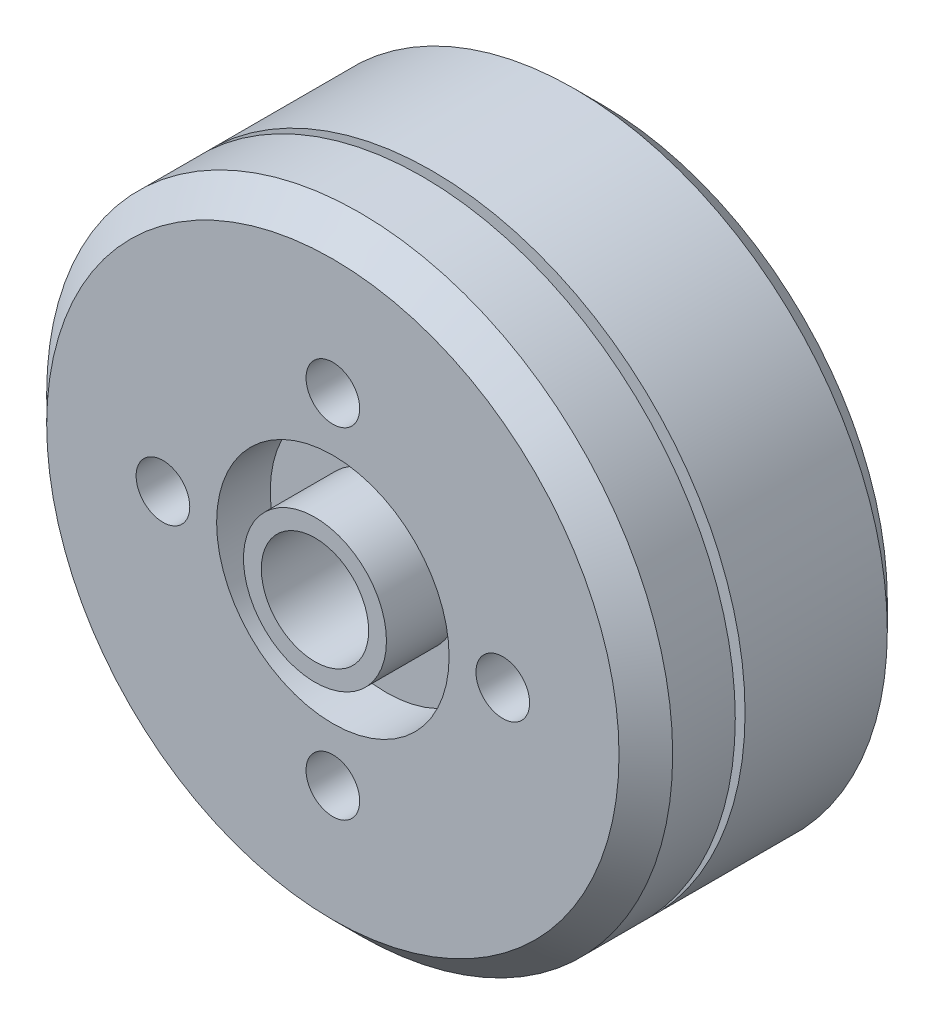
from build123d import *

# Parameters (mm, degrees)
SKETCH_1_R          = 17.5
EXTRUDE_1_DEPTH     = 15
SKETCH_2_R          = 1.5
CUT_EXTRUDE_1_DEPTH = 5
SKETCH_4_R          = 3
CUT_EXTRUDE_2_DEPTH = 20
SKETCH_5_R          = 1.5
CUT_EXTRUDE_3_DEPTH = 6
CHAMFER_1_SIZE      = 1.5
SKETCH_6_R          = 6.5
SKETCH_6_R_2        = 3.996615851
CUT_EXTRUDE_4_DEPTH = 3
SKETCH_7_R          = 3.996615851
SKETCH_7_R_2        = 3
EXTRUDE_2_DEPTH     = 1


with BuildPart() as part:
    # 草图1 → 凸台-拉伸1 (new body)
    with BuildSketch(Plane.XY):
        Circle(SKETCH_1_R)
    extrude(amount=EXTRUDE_1_DEPTH)

    # 草图2 → 切除-拉伸1 (cut)
    with BuildSketch(Plane(origin=(0, 0, 0), x_dir=(-1, 0, 0), z_dir=(0, 0, -1))):
        with Locations((0, -8)):
            Circle(SKETCH_2_R)
        with Locations((-8, 0)):
            Circle(SKETCH_2_R)
        with Locations((0, 8)):
            Circle(SKETCH_2_R)
        with Locations((8, 0)):
            Circle(SKETCH_2_R)
    extrude(amount=-CUT_EXTRUDE_1_DEPTH, mode=Mode.SUBTRACT)

    # 草图3 → 切除-旋转1 (revolve, cut)
    with BuildSketch(Plane(origin=(0, 0, 0), x_dir=(1, 0, 0), z_dir=(0, 1, 0))):
        Polygon((13.284433797, -10), (13.284433797, -9.953144571), (13.284433797, -9.453144571), (17.969347124, -9.453144571), (17.969347124, -10), align=None)
    revolve(axis=Axis((0, 0, 0), (0, 0, 1)), mode=Mode.SUBTRACT)

    # 草图4 → 切除-拉伸2 (cut)
    with BuildSketch(Plane(origin=(0, 0, 0), x_dir=(-1, 0, 0), z_dir=(0, 0, -1))):
        Circle(SKETCH_4_R)
    extrude(amount=-CUT_EXTRUDE_2_DEPTH, mode=Mode.SUBTRACT)

    # 草图5 → 切除-拉伸3 (cut)
    with BuildSketch(Plane.XY.offset(15)):
        with Locations((0, -9.5)):
            Circle(SKETCH_5_R)
        with Locations((-9.5, 0)):
            Circle(SKETCH_5_R)
        with Locations((0, 9.5)):
            Circle(SKETCH_5_R)
        with Locations((9.5, 0)):
            Circle(SKETCH_5_R)
    extrude(amount=-CUT_EXTRUDE_3_DEPTH, mode=Mode.SUBTRACT)

    # 倒角1
    chamfer_1_edges = [part.edges().sort_by_distance(p)[0] for p in [
        (-17.5, 0, 0),
        (-17.5, 0, 15),
    ]]
    chamfer(chamfer_1_edges, length=CHAMFER_1_SIZE)

    # 草图6 → 切除-拉伸4 (cut)
    with BuildSketch(Plane.XY.offset(15)):
        Circle(SKETCH_6_R)
        Circle(SKETCH_6_R_2, mode=Mode.SUBTRACT)
    extrude(amount=-CUT_EXTRUDE_4_DEPTH, mode=Mode.SUBTRACT)

    # 草图7 → 凸台-拉伸2 (add)
    with BuildSketch(Plane.XY.offset(15)):
        Circle(SKETCH_7_R)
        Circle(SKETCH_7_R_2, mode=Mode.SUBTRACT)
    extrude(amount=EXTRUDE_2_DEPTH)


solid = part.part
